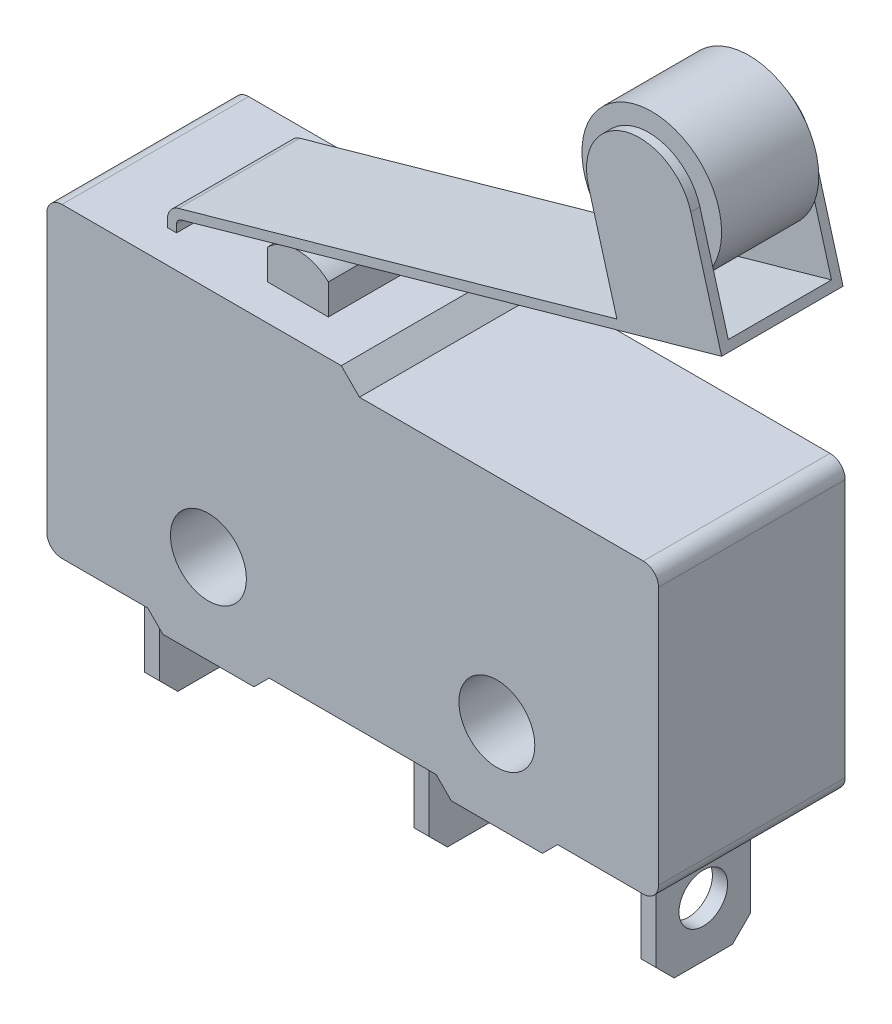
from build123d import *

# Parameters (mm, degrees)
CROQUIS1_W              = 20.15
CROQUIS1_H              = 9.5
SALIENTE_EXTRUIR1_DEPTH = 3.075
SALIENTE_EXTRUIR2_DEPTH = 6.15
CROQUIS2_3_R            = 1.25
CORTAR_EXTRUIR1_DEPTH   = 6.15
SALIENTE_EXTRUIR3_DEPTH = 6.15
CROQUIS4_W              = 0.5
CROQUIS4_H              = 3.12
SALIENTE_EXTRUIR4_DEPTH = 4
CROQUIS5_R              = 0.8
CORTAR_EXTRUIR2_DEPTH   = 19.45
REDONDEO1_R             = 0.5
CROQUIS6_W              = 2
CROQUIS6_H              = 1
SALIENTE_EXTRUIR5_DEPTH = 1.9
SALIENTE_EXTRUIR7_DEPTH = 2
SALIENTE_EXTRUIR8_DEPTH = 0.3
CROQUIS9_R              = 2.3
SALIENTE_EXTRUIR9_DEPTH = 1.6


with BuildPart() as part:
    # Croquis1 → Saliente-Extruir1 (new body, symmetric)
    with BuildSketch(Plane.XY):
        Rectangle(CROQUIS1_W, CROQUIS1_H)
    extrude(amount=SALIENTE_EXTRUIR1_DEPTH, both=True)

    # Croquis2 → Saliente-Extruir2 (add)
    with BuildSketch(Plane.XY.offset(3.075)):
        Polygon((-2.75, -4.75), (-6.75, -4.75), (-6.25, -5.25), (-3.25, -5.25), align=None)
        Polygon((6.75, -4.75), (2.75, -4.75), (3.25, -5.25), (6.25, -5.25), align=None)
    extrude(amount=-SALIENTE_EXTRUIR2_DEPTH)

    # Croquis2_3 → Cortar-Extruir1 (cut)
    with BuildSketch(Plane.XY.offset(3.075)):
        with Locations((-4.75, -2.3)):
            Circle(CROQUIS2_3_R)
        with Locations((4.75, -2.3)):
            Circle(CROQUIS2_3_R)
    extrude(amount=-CORTAR_EXTRUIR1_DEPTH, mode=Mode.SUBTRACT)

    # Croquis3 → Saliente-Extruir3 (add)
    with BuildSketch(Plane.XY.offset(3.075)):
        Polygon((-10.075, 4.75), (-10.075, 5.35), (-0.375, 5.35), (0.225, 4.75), align=None)
    extrude(amount=-SALIENTE_EXTRUIR3_DEPTH)

    # Croquis4 → Saliente-Extruir4 (add)
    with BuildSketch(Plane.XZ.offset(4.75)):
        with Locations((8.225, 0)):
            Rectangle(CROQUIS4_W, CROQUIS4_H)
        with Locations((-8.125, 0)):
            Rectangle(CROQUIS4_W, CROQUIS4_H)
        with Locations((0.755, 0)):
            Rectangle(CROQUIS4_W, CROQUIS4_H)
    extrude(amount=SALIENTE_EXTRUIR4_DEPTH)

    # Croquis5 → Cortar-Extruir2 (cut, through all)
    with BuildSketch(Plane.ZY.offset(8.375)):
        with Locations((0, -6.95)):
            Circle(CROQUIS5_R)
        Polygon((-1.56, -8.15), (-0.96, -8.75), (-1.56, -8.75), align=None)
        Polygon((1.56, -8.75), (1.56, -8.15), (0.96, -8.75), align=None)
    extrude(amount=-CORTAR_EXTRUIR2_DEPTH, mode=Mode.SUBTRACT)

    # Redondeo1
    redondeo1_edges = [part.edges().sort_by_distance(p)[0] for p in [
        (-10.075, 5.35, 0),
        (10.075, -4.75, 0),
        (-10.075, -4.75, 0),
        (10.075, 4.75, 0),
    ]]
    fillet(redondeo1_edges, radius=REDONDEO1_R)

    # Croquis6 → Saliente-Extruir5 (add, symmetric)
    with BuildSketch(Plane.XY):
        with BuildLine():
            ThreePointArc((-3.975, 6.35), (-2.975, 6.75), (-1.975, 6.35))
            Line((-1.975, 6.35), (-3.975, 6.35))
        make_face()
        with Locations((-2.975, 5.85)):
            Rectangle(CROQUIS6_W, CROQUIS6_H)
    extrude(amount=SALIENTE_EXTRUIR5_DEPTH, both=True)

    # Croquis7 → Saliente-Extruir7 (add, symmetric)
    with BuildSketch(Plane.XY):
        with BuildLine():
            Line((-6.875, 5.35), (-6.875, 5.6))
            ThreePointArc((-6.875, 5.6), (-6.834433546, 5.720751581), (-6.729190556, 5.792518528))
            Line((-6.729190556, 5.792518528), (11.078773292, 10.805144944))
            Line((11.078773292, 10.805144944), (10.997487458, 11.093922737))
            Line((10.997487458, 11.093922737), (-6.81047639, 6.08129632))
            ThreePointArc((-6.81047639, 6.08129632), (-7.073583865, 5.901878954), (-7.175, 5.6))
            Line((-7.175, 5.6), (-7.175, 5.35))
            Line((-7.175, 5.35), (-6.875, 5.35))
        make_face()
    extrude(amount=SALIENTE_EXTRUIR7_DEPTH, both=True)

    # Croquis8 → Saliente-Extruir8 (add)
    with BuildSketch(Plane.XY.offset(2)):
        with BuildLine():
            Line((10.997487458, 11.093922737), (7.628413217, 10.145588009))
            Line((7.628413217, 10.145588009), (6.693626128, 13.466532619))
            ThreePointArc((6.693626128, 13.466532619), (7.903995885, 15.625237103), (10.06270037, 14.414867346))
            Line((10.06270037, 14.414867346), (10.997487458, 11.093922737))
        make_face()
    saliente_extruir8 = extrude(amount=-SALIENTE_EXTRUIR8_DEPTH)

    # Simetr_a1: Saliente-Extruir8 across plane
    add(saliente_extruir8.mirror(Plane.XY))


with BuildPart() as body_2:
    # Croquis9 → Saliente-Extruir9 (new body, symmetric)
    with BuildSketch(Plane.XY):
        with Locations((8.378163249, 13.940699982)):
            Circle(CROQUIS9_R)
    extrude(amount=SALIENTE_EXTRUIR9_DEPTH, both=True)


solid = Compound([part.part, body_2.part])
